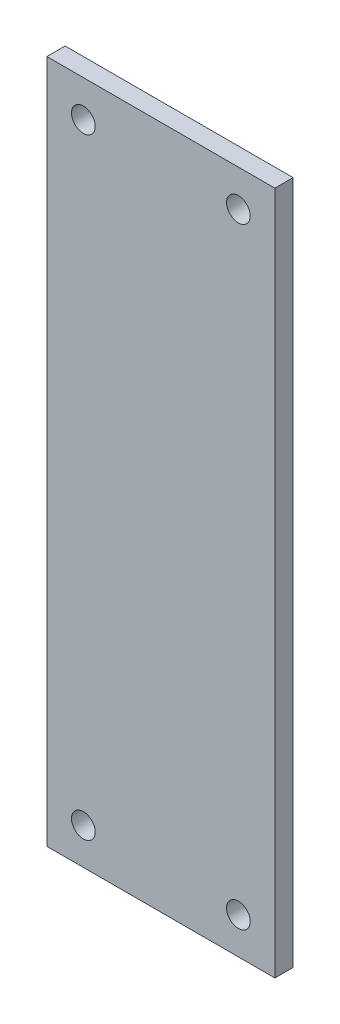
from build123d import *

# Parameters (mm, degrees)
SKETCH_1_W      = 250
SKETCH_1_H      = 750
SKETCH_1_R      = 13
EXTRUDE_1_DEPTH = 20


with BuildPart() as part:
    # Эскиз1 → Бобышка-Вытянуть1 (new body)
    with BuildSketch(Plane.XY):
        Rectangle(SKETCH_1_W, SKETCH_1_H)
        with Locations((-85, -335)):
            Circle(SKETCH_1_R, mode=Mode.SUBTRACT)
        with Locations((85, -335)):
            Circle(SKETCH_1_R, mode=Mode.SUBTRACT)
        with Locations((-85, 335)):
            Circle(SKETCH_1_R, mode=Mode.SUBTRACT)
        with Locations((85, 335)):
            Circle(SKETCH_1_R, mode=Mode.SUBTRACT)
    extrude(amount=EXTRUDE_1_DEPTH)


solid = part.part
